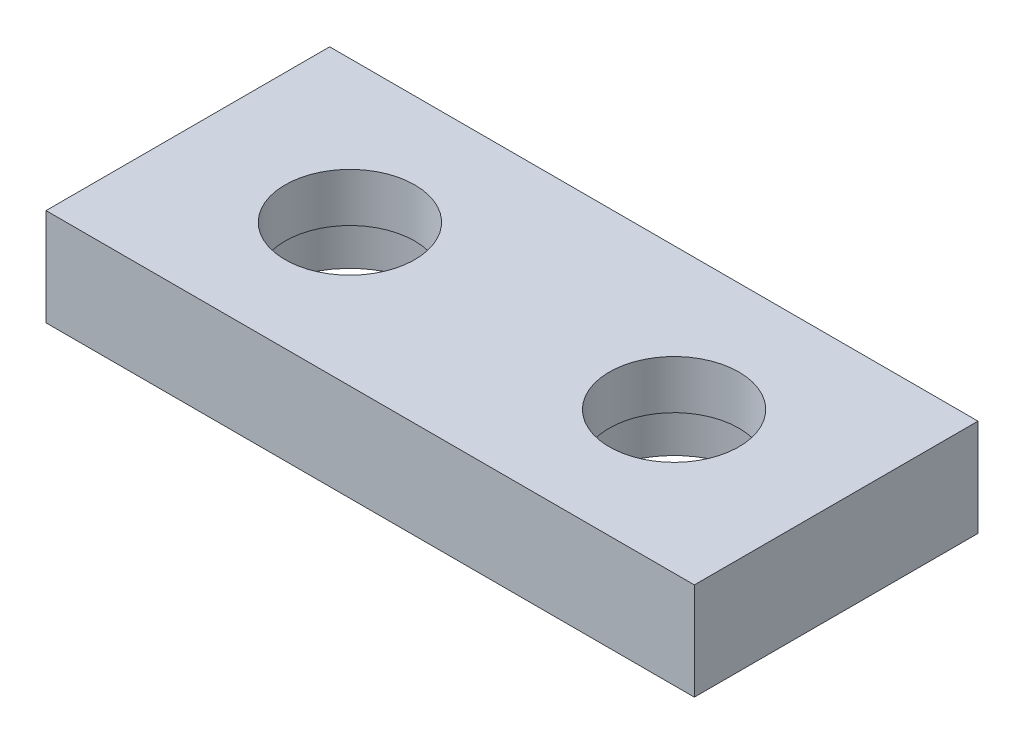
from build123d import *

# Parameters (mm, degrees)
SKETCH5_W       = 40
SKETCH5_H       = 17.5
EXTRUDE8_DEPTH  = 6
SKETCH7_R       = 5
EXTRUDE9_DEPTH  = 3
SKETCH8_R       = 4
EXTRUDE10_DEPTH = 3


with BuildPart() as part:
    # Sketch5 → Extrude8 (new body)
    with BuildSketch(Plane(origin=(0, 0, 0), x_dir=(1, 0, 0), z_dir=(0, 1, 0))):
        Rectangle(SKETCH5_W, SKETCH5_H)
    extrude(amount=EXTRUDE8_DEPTH)

    # Sketch7 → Extrude9 (cut)
    with BuildSketch(Plane.XZ):
        with Locations(Location((-10, 0, 0), (0, 0, 270))):  # turned: the seam where the file's is
            Circle(SKETCH7_R)
    extrude9 = extrude(amount=-EXTRUDE9_DEPTH, mode=Mode.SUBTRACT)

    # Sketch8 → Extrude10 (cut)
    with BuildSketch(Plane.XZ.offset(-3)):
        with Locations(Location((-10, 0, 0), (0, 0, 270))):  # turned: the seam where the file's is
            Circle(SKETCH8_R)
    extrude10 = extrude(amount=-EXTRUDE10_DEPTH, mode=Mode.SUBTRACT)

    # Mirror2: Extrude9, Extrude10 across plane
    add(extrude9.mirror(Plane(origin=(0, 0, 0), x_dir=(0, 0, 1), z_dir=(1, 0, 0))), mode=Mode.SUBTRACT)
    add(extrude10.mirror(Plane(origin=(0, 0, 0), x_dir=(0, 0, 1), z_dir=(1, 0, 0))), mode=Mode.SUBTRACT)


solid = part.part
